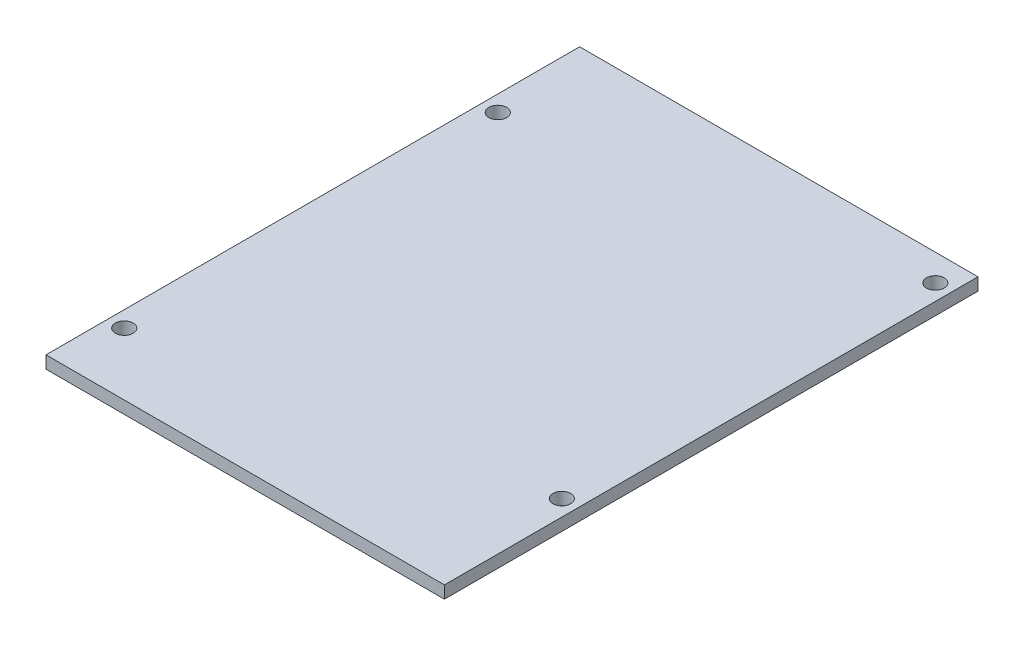
from build123d import *

# Parameters (mm, degrees)
ESQUISSE1_W             = 112
ESQUISSE1_H             = 150
BOSS_EXTRU_1_DEPTH      = 3.5
ENL_V_MAT_EXTRU_1_REACH = 5.5
ESQUISSE2_R             = 2.5


with BuildPart() as part:
    # Esquisse1 → Boss.-Extru.1 (new body)
    with BuildSketch(Plane(origin=(0, 0, 0), x_dir=(1, 0, 0), z_dir=(0, 1, 0))):
        Rectangle(ESQUISSE1_W, ESQUISSE1_H)
    extrude(amount=BOSS_EXTRU_1_DEPTH)

    # Esquisse2 → Enlèv. mat.-Extru.1 (cut, up to next)
    with BuildSketch(Plane(origin=(0, 3.5, 0), x_dir=(1, 0, 0), z_dir=(0, 1, 0)), mode=Mode.PRIVATE) as enl_v_mat_extru_1_sk1:
        with Locations((51.5, 67.5)):
            Circle(ESQUISSE2_R)
    enl_v_mat_extru_1_tool1 = extrude(enl_v_mat_extru_1_sk1.sketch, amount=-ENL_V_MAT_EXTRU_1_REACH, mode=Mode.PRIVATE) & part.part
    add(enl_v_mat_extru_1_tool1.solids().sort_by_distance((51.5, 3.5, -67.5))[0], mode=Mode.SUBTRACT)
    # Esquisse2 → Enlèv. mat.-Extru.1 (cut, up to next)
    with BuildSketch(Plane(origin=(0, 3.5, 0), x_dir=(1, 0, 0), z_dir=(0, 1, 0)), mode=Mode.PRIVATE) as enl_v_mat_extru_1_sk2:
        with Locations((-51.5, 47.5)):
            Circle(ESQUISSE2_R)
    enl_v_mat_extru_1_tool2 = extrude(enl_v_mat_extru_1_sk2.sketch, amount=-ENL_V_MAT_EXTRU_1_REACH, mode=Mode.PRIVATE) & part.part
    add(enl_v_mat_extru_1_tool2.solids().sort_by_distance((-51.5, 3.5, -47.5))[0], mode=Mode.SUBTRACT)
    # Esquisse2 → Enlèv. mat.-Extru.1 (cut, up to next)
    with BuildSketch(Plane(origin=(0, 3.5, 0), x_dir=(1, 0, 0), z_dir=(0, 1, 0)), mode=Mode.PRIVATE) as enl_v_mat_extru_1_sk3:
        with Locations((51.5, -37.5)):
            Circle(ESQUISSE2_R)
    enl_v_mat_extru_1_tool3 = extrude(enl_v_mat_extru_1_sk3.sketch, amount=-ENL_V_MAT_EXTRU_1_REACH, mode=Mode.PRIVATE) & part.part
    add(enl_v_mat_extru_1_tool3.solids().sort_by_distance((51.5, 3.5, 37.5))[0], mode=Mode.SUBTRACT)
    # Esquisse2 → Enlèv. mat.-Extru.1 (cut, up to next)
    with BuildSketch(Plane(origin=(0, 3.5, 0), x_dir=(1, 0, 0), z_dir=(0, 1, 0)), mode=Mode.PRIVATE) as enl_v_mat_extru_1_sk4:
        with Locations((-51.5, -57.5)):
            Circle(ESQUISSE2_R)
    enl_v_mat_extru_1_tool4 = extrude(enl_v_mat_extru_1_sk4.sketch, amount=-ENL_V_MAT_EXTRU_1_REACH, mode=Mode.PRIVATE) & part.part
    add(enl_v_mat_extru_1_tool4.solids().sort_by_distance((-51.5, 3.5, 57.5))[0], mode=Mode.SUBTRACT)


solid = part.part
